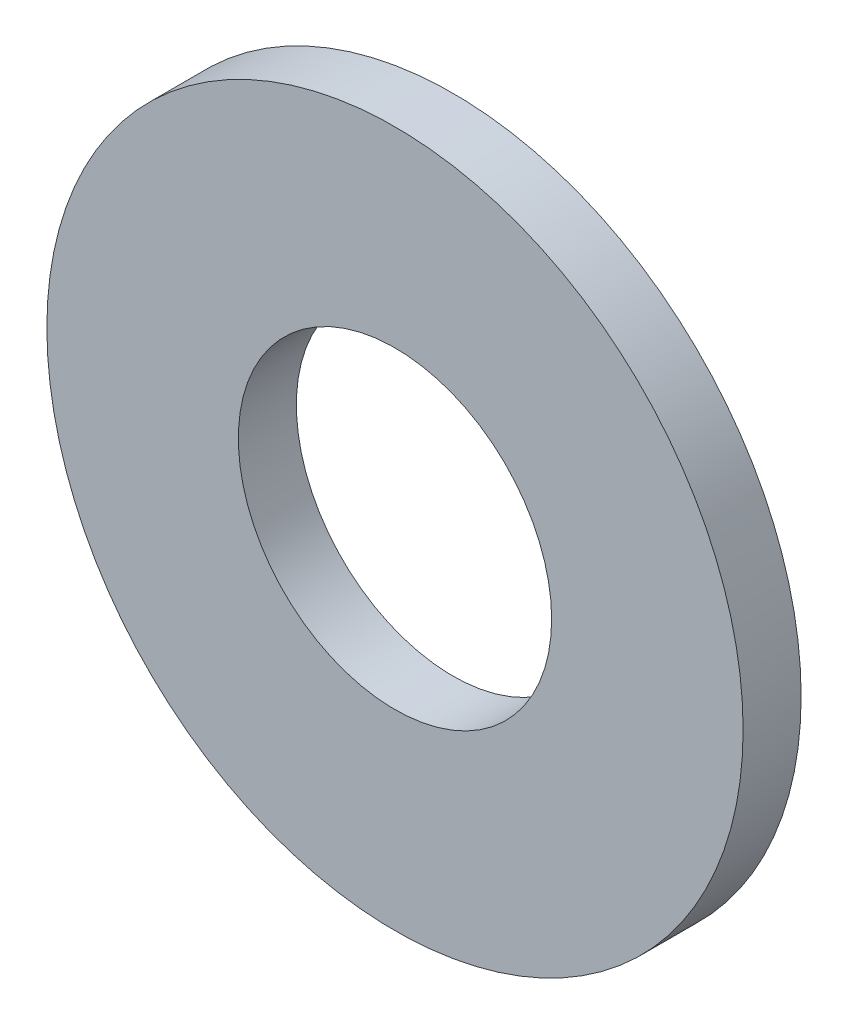
from build123d import *

# Parameters (mm, degrees)
SKETCH1_R           = 3
SKETCH1_R_2         = 1.35
BOSS_EXTRUDE1_DEPTH = 0.5


with BuildPart() as part:
    # Sketch1 → Boss-Extrude1 (new body)
    with BuildSketch(Plane.XY):
        Circle(SKETCH1_R)
        Circle(SKETCH1_R_2, mode=Mode.SUBTRACT)
    extrude(amount=BOSS_EXTRUDE1_DEPTH)


solid = part.part
